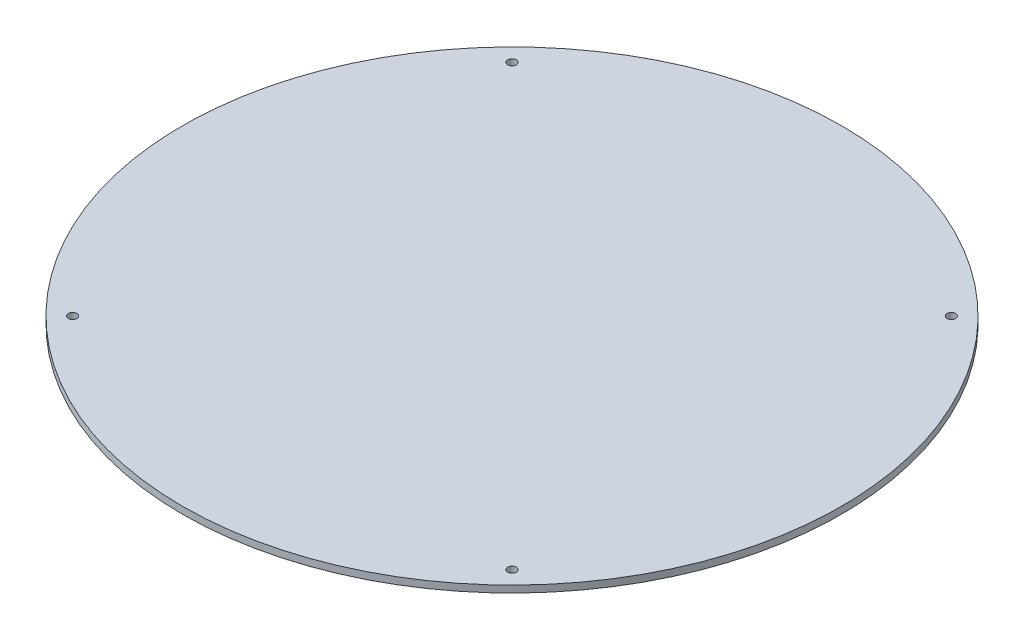
from build123d import *

# Parameters (mm, degrees)
SKETCH1_R           = 76.2
SKETCH1_R_2         = 1
BOSS_EXTRUDE1_DEPTH = 1.6


with BuildPart() as part:
    # Sketch1 → Boss-Extrude1 (new body)
    with BuildSketch(Plane(origin=(0, 0, 0), x_dir=(1, 0, 0), z_dir=(0, 1, 0))):
        Circle(SKETCH1_R)
        with Locations((50.8, 50.8)):
            Circle(SKETCH1_R_2, mode=Mode.SUBTRACT)
        with Locations((-50.8, 50.8)):
            Circle(SKETCH1_R_2, mode=Mode.SUBTRACT)
        with Locations((50.8, -50.8)):
            Circle(SKETCH1_R_2, mode=Mode.SUBTRACT)
        with Locations((-50.8, -50.8)):
            Circle(SKETCH1_R_2, mode=Mode.SUBTRACT)
    extrude(amount=BOSS_EXTRUDE1_DEPTH)


solid = part.part
